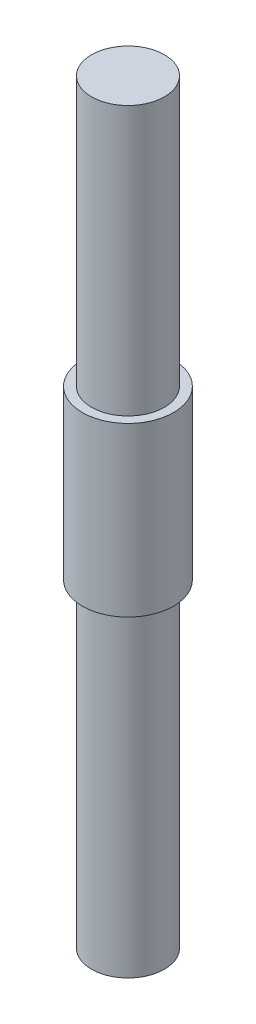
from build123d import *

# Parameters (mm, degrees)
SKETCH1_R           = 5
BOSS_EXTRUDE1_DEPTH = 18.4
SKETCH2_R           = 4
BOSS_EXTRUDE2_DEPTH = 29.5
SKETCH3_R           = 4
BOSS_EXTRUDE3_DEPTH = 35


with BuildPart() as part:
    # Sketch1 → Boss-Extrude1 (new body)
    with BuildSketch(Plane(origin=(0, 0, 0), x_dir=(1, 0, 0), z_dir=(0, 1, 0))):
        Circle(SKETCH1_R)
    extrude(amount=BOSS_EXTRUDE1_DEPTH)

    # Sketch2 → Boss-Extrude2 (add)
    with BuildSketch(Plane(origin=(0, 18.4, 0), x_dir=(1, 0, 0), z_dir=(0, 1, 0))):
        Circle(SKETCH2_R)
    extrude(amount=BOSS_EXTRUDE2_DEPTH)

    # Sketch3 → Boss-Extrude3 (add)
    with BuildSketch(Plane.XZ):
        Circle(SKETCH3_R)
    extrude(amount=BOSS_EXTRUDE3_DEPTH)


solid = part.part
